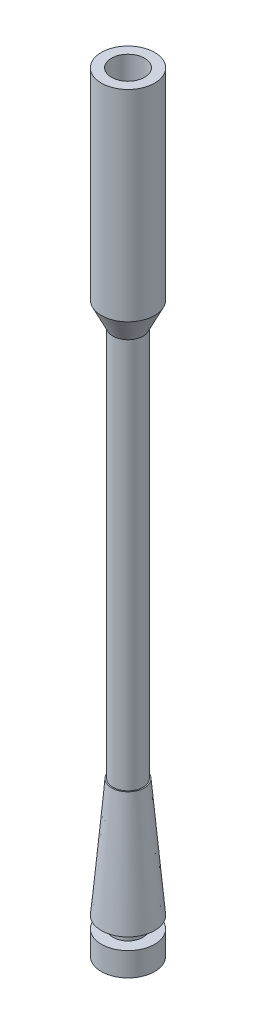
from build123d import *

# Parameters (mm, degrees)
SKETCH1_R           = 2.25
BOSS_EXTRUDE1_DEPTH = 10
BOSS_EXTRUDE1_TAPER = 5
SKETCH1_3_R         = 1.375
BOSS_EXTRUDE2_DEPTH = 1
SKETCH5_R           = 1.25
BOSS_EXTRUDE3_DEPTH = 1
SKETCH6_R           = 2.25
BOSS_EXTRUDE4_DEPTH = 2
SKETCH14_R          = 1.274517671
BOSS_EXTRUDE6_DEPTH = 33
SKETCH15_R          = 1.274517671
BOSS_EXTRUDE8_DEPTH = 2
BOSS_EXTRUDE8_DRAFT = -26
BOSS_EXTRUDE9_START = 17
SKETCH17_R          = 2.25
BOSS_EXTRUDE9_DEPTH = 17
SKETCH18_R          = 1.4
CUT_EXTRUDE2_DEPTH  = 15


with BuildPart() as part:
    # Sketch1 → Boss-Extrude1 (new body)
    with BuildSketch(Plane(origin=(0, 0, 0), x_dir=(1, 0, 0), z_dir=(0, 1, 0))):
        with Locations((-0.522013312, 0.511138034)):
            Circle(SKETCH1_R)
    extrude(amount=BOSS_EXTRUDE1_DEPTH, taper=BOSS_EXTRUDE1_TAPER)

    # Sketch1_3 → Boss-Extrude2 (add)
    with BuildSketch(Plane(origin=(0, 0, 0), x_dir=(1, 0, 0), z_dir=(0, 1, 0))):
        with Locations((-0.522013312, 0.511138034)):
            Circle(SKETCH1_3_R)
    extrude(amount=BOSS_EXTRUDE2_DEPTH)

    # Sketch5 → Boss-Extrude3 (add)
    with BuildSketch(Plane.XZ):
        with Locations((-0.522013312, -0.511138034)):
            Circle(SKETCH5_R)
    extrude(amount=BOSS_EXTRUDE3_DEPTH)

    # Sketch6 → Boss-Extrude4 (add)
    with BuildSketch(Plane.XZ.offset(1)):
        with Locations((-0.522013312, -0.511138034)):
            Circle(SKETCH6_R)
    extrude(amount=BOSS_EXTRUDE4_DEPTH)

    # Sketch14 → Boss-Extrude6 (add)
    with BuildSketch(Plane(origin=(0, 10, 0), x_dir=(1, 0, 0), z_dir=(0, 1, 0))):
        with Locations((-0.522013312, 0.511138034)):
            Circle(SKETCH14_R)
    extrude(amount=BOSS_EXTRUDE6_DEPTH)


with BuildPart() as boss_extrude8_tool:
    # Sketch15 → Boss-Extrude8 (with draft: the straight prism first)
    with BuildSketch(Plane(origin=(0, 43, 0), x_dir=(1, 0, 0), z_dir=(0, 1, 0))):
        with Locations((-0.522013312, 0.511138034)):
            Circle(SKETCH15_R)
    extrude(amount=BOSS_EXTRUDE8_DEPTH)
    # Boss-Extrude8: the draft: its side faces are tilted about the plane it starts from
    boss_extrude8_sides = [boss_extrude8_tool.faces().sort_by_distance(p)[0] for p in [
        (-1.796530983, 44, -0.511138034),
    ]]
    draft(boss_extrude8_sides, Plane(origin=(0, 43, 0), x_dir=(1, 0, 0), z_dir=(0, 1, 0)), BOSS_EXTRUDE8_DRAFT)


with BuildPart() as part_1:
    add(part.part)

    # Boss-Extrude8: add boss_extrude8_tool
    add(boss_extrude8_tool.part)

    # Sketch17 → Boss-Extrude9 (add)
    with BuildSketch(Plane(origin=(0, 45, 0), x_dir=(1, 0, 0), z_dir=(0, 1, 0)).offset(BOSS_EXTRUDE9_START)):
        with Locations((-0.522013312, 0.511138034)):
            Circle(SKETCH17_R)
    extrude(amount=-BOSS_EXTRUDE9_DEPTH)

    # Sketch18 → Cut-Extrude2 (cut)
    with BuildSketch(Plane(origin=(0, 62, 0), x_dir=(1, 0, 0), z_dir=(0, 1, 0))):
        with Locations((-0.522013312, 0.511138034)):
            Circle(SKETCH18_R)
    extrude(amount=-CUT_EXTRUDE2_DEPTH, mode=Mode.SUBTRACT)


solid = part_1.part
